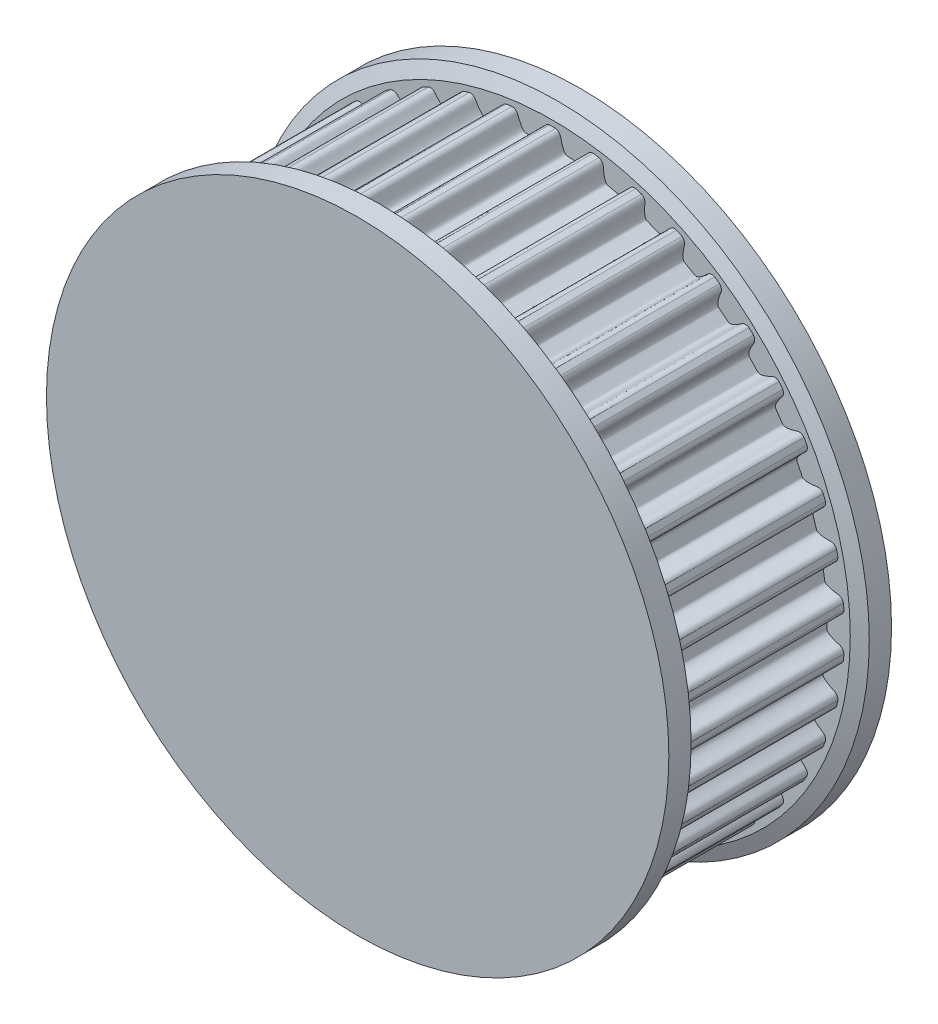
from build123d import *

# Parameters (mm, degrees)
TOOTHEXTRUDECUTGEARBELT01_DEPTH = 3.749999944
PATTERNGEARBELT01_COUNT         = 42
BOREREVOLVESKETCH_W             = 10.547999842
BOREREVOLVESKETCH_H             = 5
SKETCH1_W                       = 131.119852483
SKETCH1_H                       = 34.180202509
CUT_EXTRUDE1_DEPTH              = 15.131015007
CUT_EXTRUDE1_DEPTH_BACK         = 15.131015007
SKETCH2_R                       = 6.284324261
BOSS_EXTRUDE1_DEPTH             = 8
SKETCH3_R                       = 13.972568545
BOSS_EXTRUDE2_DEPTH             = 1
SKETCH4_R                       = 13.972568545
BOSS_EXTRUDE3_DEPTH             = 1


with BuildPart() as part:
    # SketchRevolveGearBelt01 → GearBelt01 (revolve)
    with BuildSketch(Plane(origin=(0, 0, 0), x_dir=(0, 0, -1), z_dir=(1, 0, 0))):
        Polygon((5.273999921, 0), (5.273999921, 11.869015041), (4.511999932, 11.869015041), (4.511999932, 13.217443797), (4.769626867, 13.839410236), (4.065630673, 14.131015007), (3.749999944, 13.369015019), (3.749999944, 13.112899203), (-3.749999944, 13.112899203), (-3.749999944, 13.369015019), (-4.065630673, 14.131015007), (-4.769626867, 13.839410236), (-4.511999932, 13.217443797), (-4.511999932, 11.869015041), (-5.273999921, 11.869015041), (-5.273999921, 0), align=None)
    revolve(axis=Axis((0, 0, 0), (0, 0, -1)))

    # SketchToothGearBelt01 → ToothExtrudeCutGearBelt01 (cut, symmetric)
    with BuildSketch(Plane.XY):
        with BuildLine():
            ThreePointArc((13.086186835, 0.861528152), (13.114515494, 0), (13.086186835, -0.861528152))
            add(Edge.make_bspline(
                [(13.086186835, -0.861528152), (13.086212827, -0.844234849), (13.083711825, -0.818292937), (13.075418586, -0.784673645), (13.066779523, -0.760182396), (13.055802639, -0.736645974), (13.042591832, -0.714286833), (13.027271907, -0.693316599), (13.009987984, -0.673932694), (12.990902461, -0.656321524), (12.970199567, -0.64063788), (12.948060913, -0.627073758), (12.924748531, -0.615594268), (12.8852262, -0.601574605), (12.83478638, -0.586330117), (12.775190764, -0.567480684), (12.722741318, -0.549825792), (12.673461751, -0.532186873), (12.627357579, -0.514546574), (12.584426365, -0.496909288), (12.544667317, -0.479273964), (12.508078838, -0.461640694), (12.474659018, -0.444008949), (12.444405363, -0.426377751), (12.417314847, -0.408745201), (12.393383642, -0.391107907), (12.372608449, -0.373460068), (12.354984376, -0.355792311), (12.340517883, -0.33809054), (12.329197117, -0.320336691), (12.321111244, -0.302512788), (12.316070481, -0.28461649), (12.313869237, -0.250312541), (12.317051503, -0.199994192), (12.317195558, -0.1333067), (12.317964091, -0.066656855), (12.318078162, 0), (12.317964091, 0.066656855), (12.317195558, 0.1333067), (12.317051503, 0.199994192), (12.313869237, 0.250312541), (12.316070481, 0.28461649), (12.321111244, 0.302512788), (12.329197117, 0.320336691), (12.340517883, 0.33809054), (12.354984376, 0.355792311), (12.372608449, 0.373460068), (12.393383642, 0.391107907), (12.417314847, 0.408745201), (12.444405363, 0.426377751), (12.474659018, 0.444008949), (12.508078838, 0.461640694), (12.544667317, 0.479273964), (12.584426365, 0.496909288), (12.627357579, 0.514546574), (12.673461751, 0.532186873), (12.722741318, 0.549825792), (12.775190764, 0.567480684), (12.83478638, 0.586330117), (12.8852262, 0.601574605), (12.924748531, 0.615594268), (12.948060913, 0.627073758), (12.970199567, 0.64063788), (12.990902461, 0.656321524), (13.009987984, 0.673932694), (13.027271907, 0.693316599), (13.042591832, 0.714286833), (13.055802639, 0.736645974), (13.066779523, 0.760182396), (13.075418586, 0.784673645), (13.083711825, 0.818292937), (13.086212827, 0.844234849), (13.086186835, 0.861528152)],
                knots=[0, 0, 0, 0, 0.019806294, 0.029709441, 0.039612588, 0.049515735, 0.059418882, 0.069322029, 0.079225176, 0.089128323, 0.09903147, 0.108934617, 0.118837764, 0.128740911, 0.156934142, 0.179220579, 0.200353434, 0.220339834, 0.239188208, 0.256908606, 0.273513129, 0.289016488, 0.303436768, 0.316796451, 0.329123824, 0.340454907, 0.350836097, 0.360327731, 0.369008712, 0.376982048, 0.384380365, 0.3913691, 0.398143765, 0.423626682, 0.449084455, 0.474542227, 0.5, 0.525457773, 0.550915545, 0.576373318, 0.601856235, 0.6086309, 0.615619635, 0.623017952, 0.630991288, 0.639672269, 0.649163903, 0.659545093, 0.670876176, 0.683203549, 0.696563232, 0.710983512, 0.726486871, 0.743091394, 0.760811792, 0.779660166, 0.799646566, 0.820779421, 0.843065858, 0.871259089, 0.881162236, 0.891065383, 0.90096853, 0.910871677, 0.920774824, 0.930677971, 0.940581118, 0.950484265, 0.960387412, 0.970290559, 0.980193706, 1, 1, 1, 1], degree=3))
        make_face()
    toothextrudecutgearbelt01 = extrude(amount=TOOTHEXTRUDECUTGEARBELT01_DEPTH, both=True, mode=Mode.SUBTRACT)

    # PatternGearBelt01: ToothExtrudeCutGearBelt01 ×42 about axis
    patterngearbelt01_axis = Axis((0, 0, 55), (0, 0, -1))
    for i in range(1, PATTERNGEARBELT01_COUNT):
        add(toothextrudecutgearbelt01.rotate(patterngearbelt01_axis, i * 360 / PATTERNGEARBELT01_COUNT), mode=Mode.SUBTRACT)

    # BoreRevolveSketch → BoreRevolveCut (revolve, cut)
    with BuildSketch(Plane(origin=(0, 0, 0), x_dir=(0, 0, -1), z_dir=(1, 0, 0))):
        with Locations((0, 2.5)):
            Rectangle(BOREREVOLVESKETCH_W, BOREREVOLVESKETCH_H)
    revolve(axis=Axis((0, 0, 0), (0, 0, -1)), mode=Mode.SUBTRACT)

    # Sketch1 → Cut-Extrude1 (cut, two sides)
    with BuildSketch(Plane(origin=(0, 0, 0), x_dir=(1, 0, 0), z_dir=(0, 1, 0))) as cut_extrude1_sk:
        with Locations((-34.772954093, 21.090101255)):
            Rectangle(SKETCH1_W, SKETCH1_H)
        with Locations((-34.772954093, -21.090101255)):
            Rectangle(SKETCH1_W, SKETCH1_H)
    extrude(amount=CUT_EXTRUDE1_DEPTH, mode=Mode.SUBTRACT)
    extrude(cut_extrude1_sk.sketch, amount=-CUT_EXTRUDE1_DEPTH_BACK, mode=Mode.SUBTRACT)

    # Sketch2 → Boss-Extrude1 (add)
    with BuildSketch(Plane.XY.offset(4)):
        Circle(SKETCH2_R)
    extrude(amount=-BOSS_EXTRUDE1_DEPTH)

    # Sketch3 → Boss-Extrude2 (add)
    with BuildSketch(Plane.XY.offset(4)):
        Circle(SKETCH3_R)
    extrude(amount=BOSS_EXTRUDE2_DEPTH)

    # Sketch4 → Boss-Extrude3 (add)
    with BuildSketch(Plane(origin=(0, 0, -4), x_dir=(-1, 0, 0), z_dir=(0, 0, -1))):
        Circle(SKETCH4_R)
    extrude(amount=BOSS_EXTRUDE3_DEPTH)


solid = part.part
